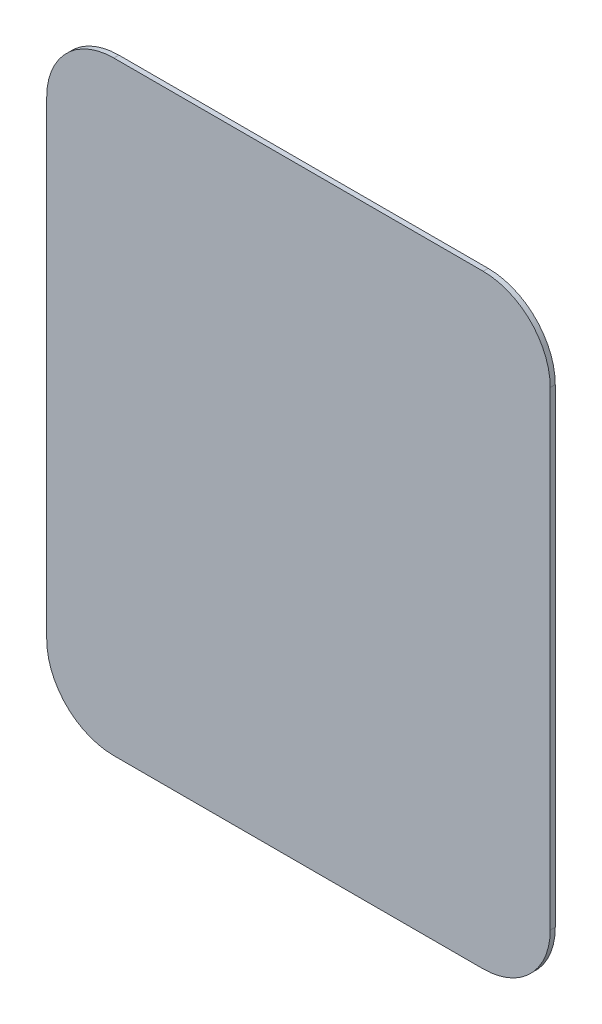
from build123d import *

# Parameters (mm, degrees)
SALIENTE_EXTRUIR1_DEPTH = 1.5
CROQUIS2_R              = 2.5
CORTAR_EXTRUIR1_DEPTH   = 1.4


with BuildPart() as part:
    # Croquis1 → Saliente-Extruir1 (new body)
    with BuildSketch(Plane.XY):
        with BuildLine():
            Line((-47.708333333, 74.739583333), (62.291666667, 74.739583333))
            ThreePointArc((62.291666667, 74.739583333), (76.43380229, 68.881718957), (82.291666667, 54.739583333))
            Line((82.291666667, 54.739583333), (82.291666667, -85.260416667))
            ThreePointArc((82.291666667, -85.260416667), (76.43380229, -99.40255229), (62.291666667, -105.260416667))
            Line((62.291666667, -105.260416667), (-47.708333333, -105.260416667))
            ThreePointArc((-47.708333333, -105.260416667), (-61.850468957, -99.40255229), (-67.708333333, -85.260416667))
            Line((-67.708333333, -85.260416667), (-67.708333333, 54.739583333))
            ThreePointArc((-67.708333333, 54.739583333), (-61.850468957, 68.881718957), (-47.708333333, 74.739583333))
        make_face()
    extrude(amount=SALIENTE_EXTRUIR1_DEPTH)

    # Croquis2 → Cortar-Extruir1 (cut)
    with BuildSketch(Plane(origin=(0, 0, 0), x_dir=(-1, 0, 0), z_dir=(0, 0, -1))):
        with Locations((-47.791666667, 45.239583333)):
            Circle(CROQUIS2_R)
        with Locations((33.208333333, 45.239583333)):
            Circle(CROQUIS2_R)
        with Locations((33.208333333, -75.760416667)):
            Circle(CROQUIS2_R)
        with Locations((-47.791666667, -75.760416667)):
            Circle(CROQUIS2_R)
    extrude(amount=-CORTAR_EXTRUIR1_DEPTH, mode=Mode.SUBTRACT)


solid = part.part
